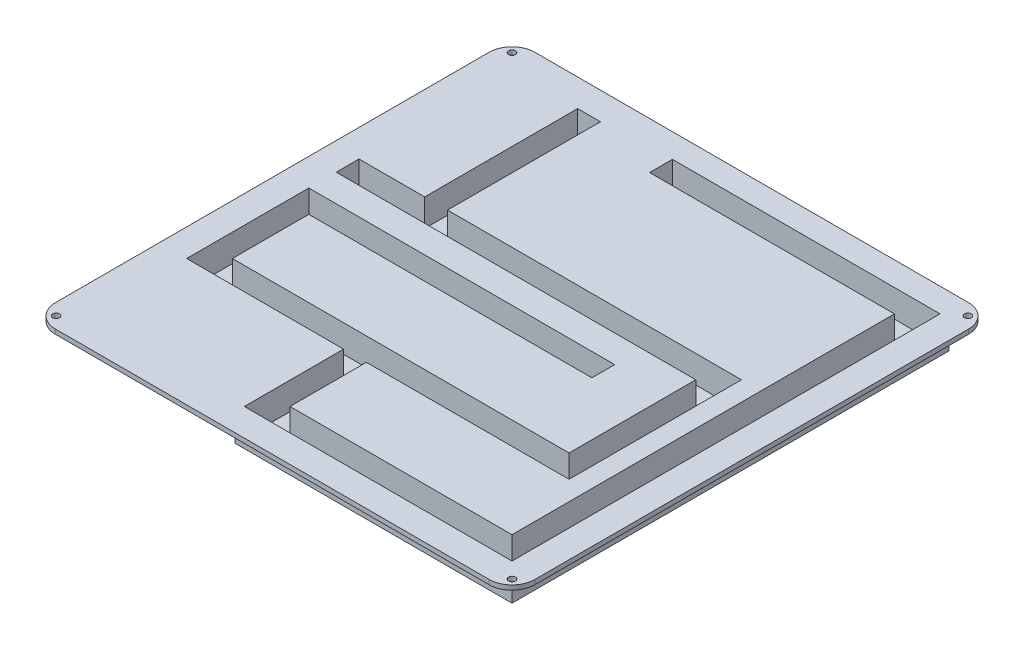
from build123d import *

# Parameters (mm, degrees)
SKETCH1_W           = 210
SKETCH1_H           = 210
MAINEXTRUDE_DEPTH   = 2
SKETCH1_6_R         = 1.5
SCREWHOLES_DEPTH    = 2
ROUNDEDCORNERS_R    = 10
TRENCH_DEPTH        = 12
BOSS_EXTRUDE3_DEPTH = 10
BOSS_EXTRUDE4_DEPTH = 2


with BuildPart() as part:
    # Sketch1 → MainExtrude (new body)
    with BuildSketch(Plane(origin=(0, 0, 0), x_dir=(1, 0, 0), z_dir=(0, 1, 0))):
        Rectangle(SKETCH1_W, SKETCH1_H)
    extrude(amount=MAINEXTRUDE_DEPTH)

    # Sketch1_6 → ScrewHoles (cut)
    with BuildSketch(Plane(origin=(0, 0, 0), x_dir=(1, 0, 0), z_dir=(0, 1, 0))):
        with Locations((-99.833273811, 99.833273811)):
            Circle(SKETCH1_6_R)
        with Locations((-99.833273811, -99.833273811)):
            Circle(SKETCH1_6_R)
        with Locations((99.833273811, -99.833273811)):
            Circle(SKETCH1_6_R)
        with Locations((99.833273811, 99.833273811)):
            Circle(SKETCH1_6_R)
    extrude(amount=SCREWHOLES_DEPTH, mode=Mode.SUBTRACT)

    # RoundedCorners
    roundedcorners_edges = [part.edges().sort_by_distance(p)[0] for p in [
        (-105, 1, -105),
        (-105, 1, 105),
        (105, 1, 105),
        (105, 1, -105),
    ]]
    fillet(roundedcorners_edges, radius=ROUNDEDCORNERS_R)

    # Sketch3 → Trench (cut)
    with BuildSketch(Plane(origin=(0, 0, 0), x_dir=(1, 0, 0), z_dir=(0, 1, 0))):
        Polygon((-64.25, 93), (-64.25, 26), (-93, 26), (-93, 16), (64.5, 16), (64.5, -39.5), (-83, -39.5), (-83, -6), (41, -6), (41, 4), (-93, 4), (-93, -49.5), (-24.25, -49.5), (-24.25, -93), (93, -93), (93, 94.5), (-24.25, 94.5), (-24.25, 84.5), (83, 84.5), (83, -83), (-14.25, -83), (-14.25, -49.5), (74.5, -49.5), (74.5, 26), (-54.25, 26), (-54.25, 93), align=None)
    extrude(amount=TRENCH_DEPTH, mode=Mode.SUBTRACT)

    # Sketch7 → Boss-Extrude3 (add)
    with BuildSketch(Plane.XZ):
        Polygon((-66.25, -95), (-52.25, -95), (-52.25, -28), (76.5, -28), (76.5, 51.5), (-12.25, 51.5), (-12.25, 81), (81, 81), (81, -82.5), (-26.25, -82.5), (-26.25, -96.5), (95, -96.5), (95, 95), (-26.25, 95), (-26.25, 51.5), (-95, 51.5), (-95, -6), (43, -6), (43, 8), (-81, 8), (-81, 37.5), (62.5, 37.5), (62.5, -14), (-95, -14), (-95, -28), (-66.25, -28), align=None)
        Polygon((-64.25, -93), (-54.25, -93), (-54.25, -26), (74.5, -26), (74.5, 49.5), (-14.25, 49.5), (-14.25, 83), (83, 83), (83, -84.5), (-24.25, -84.5), (-24.25, -94.5), (93, -94.5), (93, 93), (-24.25, 93), (-24.25, 49.5), (-93, 49.5), (-93, -4), (41, -4), (41, 6), (-83, 6), (-83, 39.5), (64.5, 39.5), (64.5, -16), (-93, -16), (-93, -26), (-64.25, -26), align=None, mode=Mode.SUBTRACT)
    extrude(amount=BOSS_EXTRUDE3_DEPTH)

    # Sketch8 → Boss-Extrude4 (add)
    with BuildSketch(Plane.XZ.offset(10)):
        Polygon((-66.25, -28), (-66.25, -95), (-52.25, -95), (-52.25, -28), (76.5, -28), (76.5, 51.5), (-12.25, 51.5), (-12.25, 81), (81, 81), (81, -82.5), (-26.25, -82.5), (-26.25, -96.5), (95, -96.5), (95, 95), (-26.25, 95), (-26.25, 51.5), (-95, 51.5), (-95, -6), (43, -6), (43, 8), (-81, 8), (-81, 37.5), (62.5, 37.5), (62.5, -14), (-95, -14), (-95, -28), align=None)
    extrude(amount=BOSS_EXTRUDE4_DEPTH)


solid = part.part
